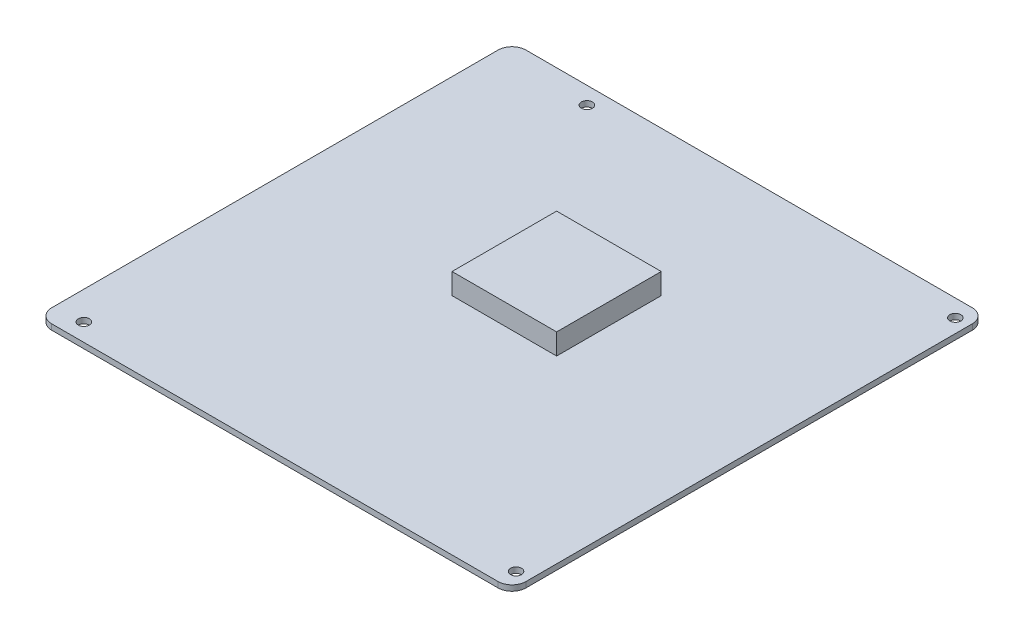
from build123d import *

# Parameters (mm, degrees)
SKETCH_1_W          = 170
SKETCH_1_H          = 170
EXTRUDE_1_DEPTH     = 2
SKETCH_2_R          = 1.98
CUT_EXTRUDE_1_DEPTH = 3
FILLET_1_R          = 5
SKETCH_4_W          = 37.5
SKETCH_4_H          = 37.5
EXTRUDE_2_DEPTH     = 7.5


with BuildPart() as part:
    # 스케치1 → 보스-돌출1 (new body)
    with BuildSketch(Plane(origin=(0, 0, 0), x_dir=(1, 0, 0), z_dir=(0, 1, 0))):
        Rectangle(SKETCH_1_W, SKETCH_1_H)
    extrude(amount=EXTRUDE_1_DEPTH)

    # 스케치2 → 컷-돌출1 (cut, through all)
    with BuildSketch(Plane(origin=(0, 2, 0), x_dir=(1, 0, 0), z_dir=(0, 1, 0))):
        with Locations((-74.84, -78.65)):
            Circle(SKETCH_2_R)
        with Locations((-51.98, 78.83)):
            Circle(SKETCH_2_R)
        with Locations((80.1, 78.83)):
            Circle(SKETCH_2_R)
        with Locations((80.1, -78.65)):
            Circle(SKETCH_2_R)
    extrude(amount=-CUT_EXTRUDE_1_DEPTH, mode=Mode.SUBTRACT)

    # 필렛1
    fillet_1_edges = [part.edges().sort_by_distance(p)[0] for p in [
        (85, 1, 85),
        (-85, 1, 85),
        (-85, 1, -85),
        (85, 1, -85),
    ]]
    fillet(fillet_1_edges, radius=FILLET_1_R)


with BuildPart() as body_2:
    # 스케치4 → 보스-돌출2 (new body)
    with BuildSketch(Plane(origin=(0, 2, 0), x_dir=(1, 0, 0), z_dir=(0, 1, 0))):
        with Locations((1.75, 14.25)):
            Rectangle(SKETCH_4_W, SKETCH_4_H)
    extrude(amount=EXTRUDE_2_DEPTH)


solid = Compound([part.part, body_2.part])
